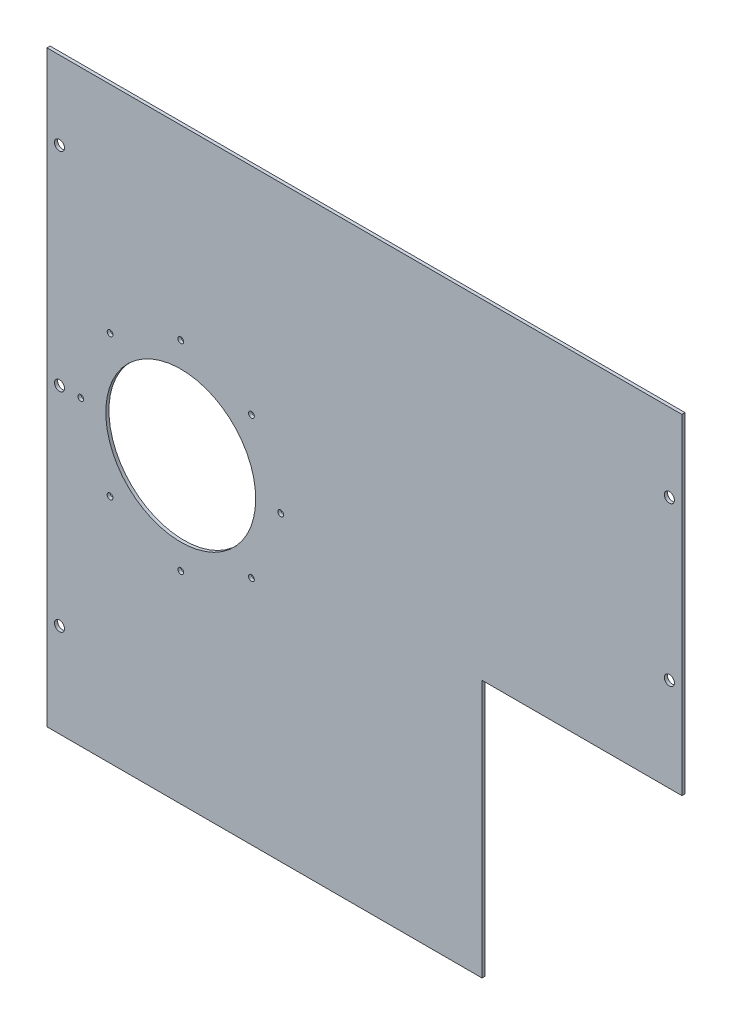
from build123d import *

# Parameters (mm, degrees)
BOSS_EXTRUDE1_DEPTH        = 1.6002
SKETCH2_R                  = 38.1
CUT_EXTRUDE1_DEPTH         = 2.6002
CIRPATTERN1_COUNT          = 8
F_10_CLEARANCE_HOLE1_D     = 5.1054
F_10_CLEARANCE_HOLE1_DEPTH = 129.53
F_10_CLEARANCE_HOLE1_TIP   = 1.533816902


with BuildPart() as part:
    # Sketch1 → Boss-Extrude1 (new body)
    with BuildSketch(Plane.XY):
        Polygon((161.3627, -22.34670835), (59.7625, -22.34670835), (59.7625, -153.41070835), (-161.3627, -153.41070835), (-161.3627, 145.48590835), (161.3627, 145.48590835), align=None)
    extrude(amount=BOSS_EXTRUDE1_DEPTH)

    # Sketch2 → Cut-Extrude1 (cut, through all)
    with BuildSketch(Plane.XY.offset(1.6002)):
        with Locations((-93.3627, 0)):
            Circle(SKETCH2_R)
    extrude(amount=-CUT_EXTRUDE1_DEPTH, mode=Mode.SUBTRACT)

    # Sketch11 → #4 Clearance Hole1 (revolve, cut)
    with BuildSketch(Plane(origin=(-93.3627, 50.8, 1.6002), x_dir=(0, -1, 0), z_dir=(1, 0, 0))):
        Polygon((0, 0), (0, 173.855187864), (1.4732, 172.97), (1.4732, 0), align=None)
    f_4_clearance_hole1 = revolve(axis=Axis((-93.3627, 50.8, 7.9502), (0, 0, -1)), mode=Mode.SUBTRACT)

    # CirPattern1: #4 Clearance Hole1 ×8 about axis
    cirpattern1_axis = Axis((-93.3627, 0, 0), (0, 0, 1))
    for i in range(1, CIRPATTERN1_COUNT):
        add(f_4_clearance_hole1.rotate(cirpattern1_axis, i * 360 / CIRPATTERN1_COUNT), mode=Mode.SUBTRACT)

    # #10 Clearance Hole1
    with Locations(Plane.XY.offset(1.6002)):
        with Locations((-155, 105.78570835), (155, 105.78570835), (-155, -105.78570835), (155, 25.27849165), (-155, 0)):
            Hole(F_10_CLEARANCE_HOLE1_D / 2, depth=F_10_CLEARANCE_HOLE1_DEPTH)
            with Locations((0, 0, -(F_10_CLEARANCE_HOLE1_DEPTH + F_10_CLEARANCE_HOLE1_TIP / 2))):  # 118° drill point
                Cone(0, F_10_CLEARANCE_HOLE1_D / 2, F_10_CLEARANCE_HOLE1_TIP, mode=Mode.SUBTRACT)


solid = part.part
